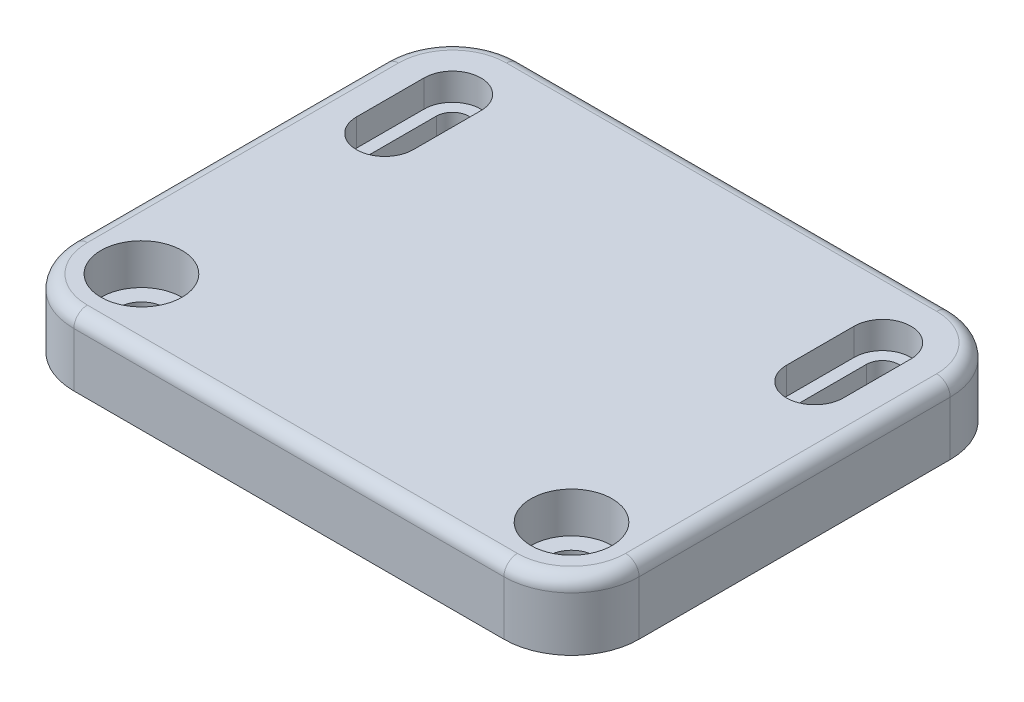
from build123d import *

# Parameters (mm, degrees)
SKETCH1_W           = 41.8
SKETCH1_H           = 33
SKETCH1_R           = 1.7
BOSS_EXTRUDE1_DEPTH = 5
FILLET1_R           = 5
FILLET2_R           = 1
CUT_EXTRUDE1_START  = -3
SKETCH2_R           = 3
SKETCH2_R_2         = 1.7
CUT_EXTRUDE1_DEPTH  = 3
CUT_EXTRUDE2_START  = -2
CUT_EXTRUDE2_DEPTH  = 2


with BuildPart() as part:
    # Sketch1 → Boss-Extrude1 (new body)
    with BuildSketch(Plane(origin=(0, 0, 0), x_dir=(1, 0, 0), z_dir=(0, 1, 0))):
        with Locations((20.9, 16.5)):
            Rectangle(SKETCH1_W, SKETCH1_H)
        with Locations((5, 5)):
            Circle(SKETCH1_R, mode=Mode.SUBTRACT)
        with Locations((36.8, 5)):
            Circle(SKETCH1_R, mode=Mode.SUBTRACT)
        with BuildLine():
            Line((3.8, 23), (3.8, 28))
            ThreePointArc((3.8, 28), (5, 29.2), (6.2, 28))
            Line((6.2, 28), (6.2, 23))
            ThreePointArc((6.2, 23), (5, 21.8), (3.8, 23))
        make_face(mode=Mode.SUBTRACT)
        with BuildLine():
            Line((35.6, 23), (35.6, 28))
            ThreePointArc((35.6, 28), (36.8, 29.2), (38, 28))
            Line((38, 28), (38, 23))
            ThreePointArc((38, 23), (36.8, 21.8), (35.6, 23))
        make_face(mode=Mode.SUBTRACT)
    extrude(amount=BOSS_EXTRUDE1_DEPTH)

    # Fillet1
    fillet1_edges = [part.edges().sort_by_distance(p)[0] for p in [
        (0, 2.5, -33),
        (41.8, 2.5, -33),
        (41.8, 2.5, 0),
        (0, 2.5, 0),
    ]]
    fillet(fillet1_edges, radius=FILLET1_R)

    # Fillet2
    fillet2_edges = [part.edges().sort_by_distance(p)[0] for p in [
        (1.464466094, 5, -1.464466094),
        (0, 5, -16.5),
        (1.464466094, 5, -31.535533906),
        (20.9, 5, -33),
        (40.335533906, 5, -31.535533906),
        (41.8, 5, -16.5),
        (40.335533906, 5, -1.464466094),
        (20.9, 5, 0),
    ]]
    fillet(fillet2_edges, radius=FILLET2_R)

    # Sketch2 → Cut-Extrude1 (cut)
    # profile 1 of 2: a face of its own
    with BuildSketch(Plane(origin=(0, 5, 0), x_dir=(1, 0, 0), z_dir=(0, 1, 0)).offset(CUT_EXTRUDE1_START)):
        with Locations((5, 5)):
            Circle(SKETCH2_R)
        with Locations((5, 5)):
            Circle(SKETCH2_R_2, mode=Mode.SUBTRACT)
    # profile 2 of 2: a face of its own
    with BuildSketch(Plane(origin=(0, 5, 0), x_dir=(1, 0, 0), z_dir=(0, 1, 0)).offset(CUT_EXTRUDE1_START)):
        with Locations((36.8, 5)):
            Circle(SKETCH2_R)
        with Locations((36.8, 5)):
            Circle(SKETCH2_R_2, mode=Mode.SUBTRACT)
    extrude(amount=CUT_EXTRUDE1_DEPTH, mode=Mode.SUBTRACT)

    # Sketch2_3 → Cut-Extrude2 (cut)
    # profile 1 of 2: a face of its own
    with BuildSketch(Plane(origin=(0, 5, 0), x_dir=(1, 0, 0), z_dir=(0, 1, 0)).offset(CUT_EXTRUDE2_START)):
        with BuildLine():
            Line((7.1, 23), (7.1, 28))
            ThreePointArc((7.1, 28), (5, 30.1), (2.9, 28))
            Line((2.9, 28), (2.9, 23))
            ThreePointArc((2.9, 23), (5, 20.9), (7.1, 23))
        make_face()
        with BuildLine():
            Line((6.2, 28), (6.2, 23))
            ThreePointArc((6.2, 23), (5, 21.8), (3.8, 23))
            Line((3.8, 23), (3.8, 28))
            ThreePointArc((3.8, 28), (5, 29.2), (6.2, 28))
        make_face(mode=Mode.SUBTRACT)
    # profile 2 of 2: a face of its own
    with BuildSketch(Plane(origin=(0, 5, 0), x_dir=(1, 0, 0), z_dir=(0, 1, 0)).offset(CUT_EXTRUDE2_START)):
        with BuildLine():
            Line((38.9, 23), (38.9, 28))
            ThreePointArc((38.9, 28), (36.8, 30.1), (34.7, 28))
            Line((34.7, 28), (34.7, 23))
            ThreePointArc((34.7, 23), (36.8, 20.9), (38.9, 23))
        make_face()
        with BuildLine():
            Line((38, 28), (38, 23))
            ThreePointArc((38, 23), (36.8, 21.8), (35.6, 23))
            Line((35.6, 23), (35.6, 28))
            ThreePointArc((35.6, 28), (36.8, 29.2), (38, 28))
        make_face(mode=Mode.SUBTRACT)
    extrude(amount=CUT_EXTRUDE2_DEPTH, mode=Mode.SUBTRACT)


solid = part.part
